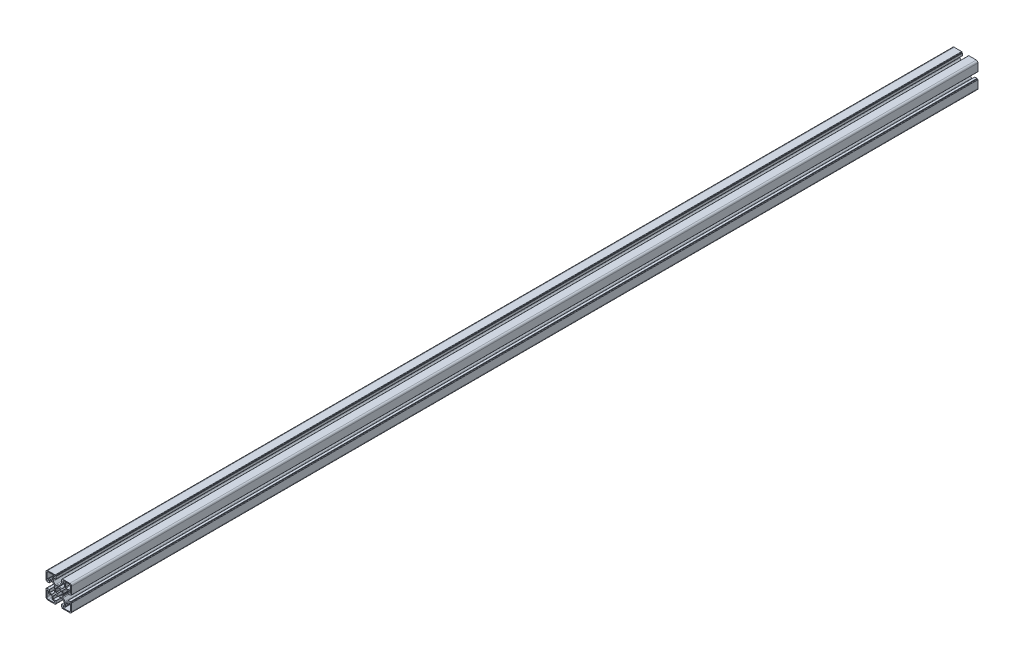
from build123d import *

# Parameters (mm, degrees)
BASE_EXTRUDE_DEPTH  = 1600
M12_HOLE_LEFT_D     = 10.8
M12_HOLE_LEFT_DEPTH = 55
M12_HOLE_LEFT_TIP   = 3.244647343


with BuildPart() as part:
    # Sketch1 → Base-Extrude (new body)
    with BuildSketch(Plane.XY):
        with BuildLine():
            Line((7.973976585, 0.792591518), (7.540060475, 0.046829556))
            ThreePointArc((7.540060475, 0.046829556), (7.534295984, 0.023675638), (7.531329941, 0))
            ThreePointArc((7.531329941, 0), (7.534295984, -0.023675638), (7.540060475, -0.046829556))
            Line((7.540060475, -0.046829556), (7.973976585, -0.792591518))
            ThreePointArc((7.973976585, -0.792591518), (7.996666421, -0.851255641), (8.000014047, -0.914065683))
            ThreePointArc((8.000014047, -0.914065683), (7.719730741, -2.298395946), (7.20036345, -3.611859543))
            ThreePointArc((7.20036345, -3.611859543), (7.018857217, -4.793954471), (7.563483933, -5.85869607))
            Line((7.563483933, -5.85869607), (11.129779889, -9.424988026))
            ThreePointArc((11.129779889, -9.424988026), (11.760624613, -9.84650461), (12.504756513, -9.99452154))
            Line((12.504756513, -9.99452154), (16.316902451, -9.99452154))
            ThreePointArc((16.316902451, -9.99452154), (16.458324055, -9.935942793), (16.516902802, -9.794521189))
            Line((16.516902802, -9.794521189), (16.516902802, -5.200014226))
            ThreePointArc((16.516902802, -5.200014226), (16.575481548, -5.058592621), (16.716903152, -5.000013875))
            Line((16.716903152, -5.000013875), (20.719599904, -5.000013875))
            ThreePointArc((20.719599904, -5.000013875), (20.931731427, -5.087881629), (21.01959918, -5.300013151))
            Line((21.01959918, -5.300013151), (21.01959918, -5.500004099))
            ThreePointArc((21.01959918, -5.500004099), (21.10746708, -5.712135974), (21.319598956, -5.800003874))
            Line((21.319598956, -5.800003874), (21.999979514, -5.800003874))
            ThreePointArc((21.999979514, -5.800003874), (22.35353264, -5.946450374), (22.49997914, -6.300003501))
            Line((22.49997914, -6.300003501), (22.49997914, -19.500016116))
            ThreePointArc((22.49997914, -19.500016116), (21.62130014, -21.621334875), (19.499981381, -22.500013875))
            Line((19.499981381, -22.500013875), (6.375709012, -22.500013875))
            ThreePointArc((6.375709012, -22.500013875), (6.022155886, -22.353567375), (5.875709386, -22.000014249))
            Line((5.875709386, -22.000014249), (5.875709386, -21.30001315))
            ThreePointArc((5.875709386, -21.30001315), (5.787841632, -21.087881628), (5.57571011, -21.000013874))
            Line((5.57571011, -21.000013874), (5.299998776, -21.000013874))
            ThreePointArc((5.299998776, -21.000013874), (5.087867607, -20.912146267), (5, -20.700015099))
            Line((5, -20.700015099), (5, -16.666812433))
            ThreePointArc((5, -16.666812433), (5.058578893, -16.525390475), (5.200000851, -16.466811582))
            Line((5.200000851, -16.466811582), (9.905385218, -16.466811582))
            ThreePointArc((9.905385218, -16.466811582), (10.046806822, -16.408232835), (10.105385569, -16.266811231))
            Line((10.105385569, -16.266811231), (10.105385569, -12.471582956))
            ThreePointArc((10.105385569, -12.471582956), (9.953144588, -11.706215861), (9.519598955, -11.057368968))
            Line((9.519598955, -11.057368968), (5.944897989, -7.482668002))
            ThreePointArc((5.944897989, -7.482668002), (4.854601835, -6.967833724), (3.666499237, -7.173289937))
            ThreePointArc((3.666499237, -7.173289937), (2.309136684, -7.713848333), (0.876396038, -8.000013875))
            ThreePointArc((0.876396038, -8.000013875), (0.81356491, -7.997088573), (0.754749577, -7.974793627))
            Line((0.754749577, -7.974793627), (0.11262846, -7.606936933))
            ThreePointArc((0.11262846, -7.606936933), (0.062963903, -7.559088739), (0, -7.530953975))
            ThreePointArc((0, -7.530953975), (-0.062963903, -7.559088739), (-0.11262846, -7.606936933))
            Line((-0.11262846, -7.606936933), (-0.754749577, -7.974793627))
            ThreePointArc((-0.754749577, -7.974793627), (-0.81356491, -7.997088573), (-0.876396038, -8.000013875))
            ThreePointArc((-0.876396038, -8.000013875), (-2.309136684, -7.713848333), (-3.666499237, -7.173289937))
            ThreePointArc((-3.666499237, -7.173289937), (-4.854601835, -6.967833724), (-5.944897989, -7.482668002))
            Line((-5.944897989, -7.482668002), (-9.519598955, -11.057368968))
            ThreePointArc((-9.519598955, -11.057368968), (-9.953144588, -11.706215861), (-10.105385569, -12.471582956))
            Line((-10.105385569, -12.471582956), (-10.105385569, -16.266811231))
            ThreePointArc((-10.105385569, -16.266811231), (-10.046806822, -16.408232835), (-9.905385218, -16.466811582))
            Line((-9.905385218, -16.466811582), (-5.200000851, -16.466811582))
            ThreePointArc((-5.200000851, -16.466811582), (-5.058578893, -16.525390475), (-5, -16.666812433))
            Line((-5, -16.666812433), (-5, -20.700015099))
            ThreePointArc((-5, -20.700015099), (-5.087867607, -20.912146267), (-5.299998776, -21.000013874))
            Line((-5.299998776, -21.000013874), (-5.57571011, -21.000013874))
            ThreePointArc((-5.57571011, -21.000013874), (-5.787841632, -21.087881628), (-5.875709386, -21.30001315))
            Line((-5.875709386, -21.30001315), (-5.875709386, -22.000014249))
            ThreePointArc((-5.875709386, -22.000014249), (-6.022155886, -22.353567375), (-6.375709012, -22.500013875))
            Line((-6.375709012, -22.500013875), (-19.499981381, -22.500013875))
            ThreePointArc((-19.499981381, -22.500013875), (-21.62130014, -21.621334875), (-22.49997914, -19.500016116))
            Line((-22.49997914, -19.500016116), (-22.49997914, -6.300003501))
            ThreePointArc((-22.49997914, -6.300003501), (-22.35353264, -5.946450374), (-21.999979514, -5.800003874))
            Line((-21.999979514, -5.800003874), (-21.319598956, -5.800003874))
            ThreePointArc((-21.319598956, -5.800003874), (-21.10746708, -5.712135974), (-21.01959918, -5.500004099))
            Line((-21.01959918, -5.500004099), (-21.01959918, -5.300013151))
            ThreePointArc((-21.01959918, -5.300013151), (-20.931731427, -5.087881629), (-20.719599904, -5.000013875))
            Line((-20.719599904, -5.000013875), (-16.716903152, -5.000013875))
            ThreePointArc((-16.716903152, -5.000013875), (-16.575481548, -5.058592621), (-16.516902802, -5.200014226))
            Line((-16.516902802, -5.200014226), (-16.516902802, -9.794521189))
            ThreePointArc((-16.516902802, -9.794521189), (-16.458324055, -9.935942793), (-16.316902451, -9.99452154))
            Line((-16.316902451, -9.99452154), (-12.504756513, -9.99452154))
            ThreePointArc((-12.504756513, -9.99452154), (-11.760624613, -9.84650461), (-11.129779889, -9.424988026))
            Line((-11.129779889, -9.424988026), (-7.563483933, -5.85869607))
            ThreePointArc((-7.563483933, -5.85869607), (-7.018857217, -4.793954471), (-7.20036345, -3.611859543))
            ThreePointArc((-7.20036345, -3.611859543), (-7.719730741, -2.298395946), (-8.000014047, -0.914065683))
            ThreePointArc((-8.000014047, -0.914065683), (-7.996666421, -0.851255641), (-7.973976585, -0.792591518))
            Line((-7.973976585, -0.792591518), (-7.540060475, -0.046829556))
            ThreePointArc((-7.540060475, -0.046829556), (-7.534295984, -0.023675638), (-7.531329941, 0))
            ThreePointArc((-7.531329941, 0), (-7.534295984, 0.023675638), (-7.540060475, 0.046829556))
            Line((-7.540060475, 0.046829556), (-7.973976585, 0.792591518))
            ThreePointArc((-7.973976585, 0.792591518), (-7.996666421, 0.851255641), (-8.000014047, 0.914065683))
            ThreePointArc((-8.000014047, 0.914065683), (-7.719730741, 2.298395946), (-7.20036345, 3.611859543))
            ThreePointArc((-7.20036345, 3.611859543), (-7.018857217, 4.793954471), (-7.563483933, 5.85869607))
            Line((-7.563483933, 5.85869607), (-11.129779889, 9.424988026))
            ThreePointArc((-11.129779889, 9.424988026), (-11.760624613, 9.84650461), (-12.504756513, 9.99452154))
            Line((-12.504756513, 9.99452154), (-16.316902451, 9.99452154))
            ThreePointArc((-16.316902451, 9.99452154), (-16.458324055, 9.935942793), (-16.516902802, 9.794521189))
            Line((-16.516902802, 9.794521189), (-16.516902802, 5.200014226))
            ThreePointArc((-16.516902802, 5.200014226), (-16.575481548, 5.058592621), (-16.716903152, 5.000013875))
            Line((-16.716903152, 5.000013875), (-20.719599904, 5.000013875))
            ThreePointArc((-20.719599904, 5.000013875), (-20.931731427, 5.087881629), (-21.01959918, 5.300013151))
            Line((-21.01959918, 5.300013151), (-21.01959918, 5.500004099))
            ThreePointArc((-21.01959918, 5.500004099), (-21.10746708, 5.712135974), (-21.319598956, 5.800003874))
            Line((-21.319598956, 5.800003874), (-21.999979514, 5.800003874))
            ThreePointArc((-21.999979514, 5.800003874), (-22.35353264, 5.946450374), (-22.49997914, 6.300003501))
            Line((-22.49997914, 6.300003501), (-22.49997914, 19.500016116))
            ThreePointArc((-22.49997914, 19.500016116), (-21.62130014, 21.621334875), (-19.499981381, 22.500013875))
            Line((-19.499981381, 22.500013875), (-6.375709012, 22.500013875))
            ThreePointArc((-6.375709012, 22.500013875), (-6.022155886, 22.353567375), (-5.875709386, 22.000014249))
            Line((-5.875709386, 22.000014249), (-5.875709386, 21.30001315))
            ThreePointArc((-5.875709386, 21.30001315), (-5.787841632, 21.087881628), (-5.57571011, 21.000013874))
            Line((-5.57571011, 21.000013874), (-5.299998776, 21.000013874))
            ThreePointArc((-5.299998776, 21.000013874), (-5.087867607, 20.912146267), (-5, 20.700015099))
            Line((-5, 20.700015099), (-5, 16.666812433))
            ThreePointArc((-5, 16.666812433), (-5.058578893, 16.525390475), (-5.200000851, 16.466811582))
            Line((-5.200000851, 16.466811582), (-9.905385218, 16.466811582))
            ThreePointArc((-9.905385218, 16.466811582), (-10.046806822, 16.408232835), (-10.105385569, 16.266811231))
            Line((-10.105385569, 16.266811231), (-10.105385569, 12.471582956))
            ThreePointArc((-10.105385569, 12.471582956), (-9.953144588, 11.706215861), (-9.519598955, 11.057368968))
            Line((-9.519598955, 11.057368968), (-5.944897989, 7.482668002))
            ThreePointArc((-5.944897989, 7.482668002), (-4.854601835, 6.967833724), (-3.666499237, 7.173289937))
            ThreePointArc((-3.666499237, 7.173289937), (-2.309136684, 7.713848333), (-0.876396038, 8.000013875))
            ThreePointArc((-0.876396038, 8.000013875), (-0.81356491, 7.997088573), (-0.754749577, 7.974793627))
            Line((-0.754749577, 7.974793627), (-0.11262846, 7.606936933))
            ThreePointArc((-0.11262846, 7.606936933), (-0.062963903, 7.559088739), (0, 7.530953975))
            ThreePointArc((0, 7.530953975), (0.062963903, 7.559088739), (0.11262846, 7.606936933))
            Line((0.11262846, 7.606936933), (0.754749577, 7.974793627))
            ThreePointArc((0.754749577, 7.974793627), (0.81356491, 7.997088573), (0.876396038, 8.000013875))
            ThreePointArc((0.876396038, 8.000013875), (2.309136684, 7.713848333), (3.666499237, 7.173289937))
            ThreePointArc((3.666499237, 7.173289937), (4.854601835, 6.967833724), (5.944897989, 7.482668002))
            Line((5.944897989, 7.482668002), (9.519598955, 11.057368968))
            ThreePointArc((9.519598955, 11.057368968), (9.953144588, 11.706215861), (10.105385569, 12.471582956))
            Line((10.105385569, 12.471582956), (10.105385569, 16.266811231))
            ThreePointArc((10.105385569, 16.266811231), (10.046806822, 16.408232835), (9.905385218, 16.466811582))
            Line((9.905385218, 16.466811582), (5.200000851, 16.466811582))
            ThreePointArc((5.200000851, 16.466811582), (5.058578893, 16.525390475), (5, 16.666812433))
            Line((5, 16.666812433), (5, 20.700015099))
            ThreePointArc((5, 20.700015099), (5.087867607, 20.912146267), (5.299998776, 21.000013874))
            Line((5.299998776, 21.000013874), (5.57571011, 21.000013874))
            ThreePointArc((5.57571011, 21.000013874), (5.787841632, 21.087881628), (5.875709386, 21.30001315))
            Line((5.875709386, 21.30001315), (5.875709386, 22.000014249))
            ThreePointArc((5.875709386, 22.000014249), (6.022155886, 22.353567375), (6.375709012, 22.500013875))
            Line((6.375709012, 22.500013875), (19.499981381, 22.500013875))
            ThreePointArc((19.499981381, 22.500013875), (21.62130014, 21.621334875), (22.49997914, 19.500016116))
            Line((22.49997914, 19.500016116), (22.49997914, 6.300003501))
            ThreePointArc((22.49997914, 6.300003501), (22.35353264, 5.946450374), (21.999979514, 5.800003874))
            Line((21.999979514, 5.800003874), (21.319598956, 5.800003874))
            ThreePointArc((21.319598956, 5.800003874), (21.10746708, 5.712135974), (21.01959918, 5.500004099))
            Line((21.01959918, 5.500004099), (21.01959918, 5.300013151))
            ThreePointArc((21.01959918, 5.300013151), (20.931731427, 5.087881629), (20.719599904, 5.000013875))
            Line((20.719599904, 5.000013875), (16.716903152, 5.000013875))
            ThreePointArc((16.716903152, 5.000013875), (16.575481548, 5.058592621), (16.516902802, 5.200014226))
            Line((16.516902802, 5.200014226), (16.516902802, 9.794521189))
            ThreePointArc((16.516902802, 9.794521189), (16.458324055, 9.935942793), (16.316902451, 9.99452154))
            Line((16.316902451, 9.99452154), (12.504756513, 9.99452154))
            ThreePointArc((12.504756513, 9.99452154), (11.760624613, 9.84650461), (11.129779889, 9.424988026))
            Line((11.129779889, 9.424988026), (7.563483933, 5.85869607))
            ThreePointArc((7.563483933, 5.85869607), (7.018857217, 4.793954471), (7.20036345, 3.611859543))
            ThreePointArc((7.20036345, 3.611859543), (7.719730741, 2.298395946), (8.000014047, 0.914065683))
            ThreePointArc((8.000014047, 0.914065683), (7.996666421, 0.851255641), (7.973976585, 0.792591518))
        make_face()
        with BuildLine():
            Line((10.549978885, 18.000013874), (8.999979138, 18.000013874))
            ThreePointArc((8.999979138, 18.000013874), (7.499979138, 19.500013874), (8.999979138, 21.000013874))
            Line((8.999979138, 21.000013874), (18.499981006, 21.000013874))
            ThreePointArc((18.499981006, 21.000013874), (20.267746638, 20.267781374), (20.999979138, 18.500015742))
            Line((20.999979138, 18.500015742), (20.999979138, 9.000204874))
            ThreePointArc((20.999979138, 9.000204874), (19.499979138, 7.500204874), (17.999979138, 9.000204874))
            Line((17.999979138, 9.000204874), (17.999979138, 10.550013621))
            ThreePointArc((17.999979138, 10.550013621), (17.707086138, 11.257119874), (16.999979885, 11.550012874))
            Line((16.999979885, 11.550012874), (12.549977391, 11.550012874))
            ThreePointArc((12.549977391, 11.550012874), (11.842871138, 11.842905874), (11.549978138, 12.550012127))
            Line((11.549978138, 12.550012127), (11.549978138, 17.000014621))
            ThreePointArc((11.549978138, 17.000014621), (11.257085138, 17.707120874), (10.549978885, 18.000013874))
        make_face(mode=Mode.SUBTRACT)
        with BuildLine():
            Line((-0.867388737, 4.924188946), (-0.96752168, 5.481112935))
            ThreePointArc((-0.96752168, 5.481112935), (-1.187855719, 5.829589164), (-1.595071417, 5.894072848))
            ThreePointArc((-1.595071417, 5.894072848), (-2.338895973, 5.643477696), (-3.04438497, 5.299445466))
            ThreePointArc((-3.04438497, 5.299445466), (-3.284615367, 4.964275075), (-3.191311906, 4.562598216))
            Line((-3.191311906, 4.562598216), (-2.864000421, 4.09847552))
            ThreePointArc((-2.864000421, 4.09847552), (-3.53013295, 3.540926624), (-4.08971289, 2.876499344))
            Line((-4.08971289, 2.876499344), (-4.566777651, 3.208162503))
            ThreePointArc((-4.566777651, 3.208162503), (-4.968960845, 3.298770682), (-5.302497889, 3.056460542))
            ThreePointArc((-5.302497889, 3.056460542), (-5.651259984, 2.353310881), (-5.906847665, 1.611199444))
            ThreePointArc((-5.906847665, 1.611199444), (-5.839752063, 1.204293023), (-5.489730697, 0.98621116))
            Line((-5.489730697, 0.98621116), (-4.920545766, 0.887822825))
            ThreePointArc((-4.920545766, 0.887822825), (-4.980096828, 0.445685524), (-5, 0))
            ThreePointArc((-5, 0), (-4.980096828, -0.445685524), (-4.920545766, -0.887822825))
            Line((-4.920545766, -0.887822825), (-5.489730697, -0.98621116))
            ThreePointArc((-5.489730697, -0.98621116), (-5.839752063, -1.204293023), (-5.906847665, -1.611199444))
            ThreePointArc((-5.906847665, -1.611199444), (-5.651259984, -2.353310881), (-5.302497889, -3.056460542))
            ThreePointArc((-5.302497889, -3.056460542), (-4.968960845, -3.298770682), (-4.566777651, -3.208162503))
            Line((-4.566777651, -3.208162503), (-4.08971289, -2.876499344))
            ThreePointArc((-4.08971289, -2.876499344), (-3.53013295, -3.540926624), (-2.864000421, -4.09847552))
            Line((-2.864000421, -4.09847552), (-3.191311906, -4.562598216))
            ThreePointArc((-3.191311906, -4.562598216), (-3.284615367, -4.964275075), (-3.04438497, -5.299445466))
            ThreePointArc((-3.04438497, -5.299445466), (-2.338895973, -5.643477696), (-1.595071417, -5.894072848))
            ThreePointArc((-1.595071417, -5.894072848), (-1.187855719, -5.829589164), (-0.96752168, -5.481112935))
            Line((-0.96752168, -5.481112935), (-0.867388737, -4.924188946))
            ThreePointArc((-0.867388737, -4.924188946), (0, -5), (0.867388737, -4.924188946))
            Line((0.867388737, -4.924188946), (0.96752168, -5.481112935))
            ThreePointArc((0.96752168, -5.481112935), (1.187855719, -5.829589164), (1.595071417, -5.894072848))
            ThreePointArc((1.595071417, -5.894072848), (2.338895973, -5.643477696), (3.04438497, -5.299445466))
            ThreePointArc((3.04438497, -5.299445466), (3.284615367, -4.964275075), (3.191311906, -4.562598216))
            Line((3.191311906, -4.562598216), (2.864000421, -4.09847552))
            ThreePointArc((2.864000421, -4.09847552), (3.53013295, -3.540926624), (4.08971289, -2.876499344))
            Line((4.08971289, -2.876499344), (4.566777651, -3.208162503))
            ThreePointArc((4.566777651, -3.208162503), (4.968960845, -3.298770682), (5.302497889, -3.056460542))
            ThreePointArc((5.302497889, -3.056460542), (5.651259984, -2.353310881), (5.906847665, -1.611199444))
            ThreePointArc((5.906847665, -1.611199444), (5.839752063, -1.204293023), (5.489730697, -0.98621116))
            Line((5.489730697, -0.98621116), (4.920545766, -0.887822825))
            ThreePointArc((4.920545766, -0.887822825), (4.980096828, -0.445685524), (5, 0))
            ThreePointArc((5, 0), (4.980096828, 0.445685524), (4.920545766, 0.887822825))
            Line((4.920545766, 0.887822825), (5.489730697, 0.98621116))
            ThreePointArc((5.489730697, 0.98621116), (5.839752063, 1.204293023), (5.906847665, 1.611199444))
            ThreePointArc((5.906847665, 1.611199444), (5.651259984, 2.353310881), (5.302497889, 3.056460542))
            ThreePointArc((5.302497889, 3.056460542), (4.968960845, 3.298770682), (4.566777651, 3.208162503))
            Line((4.566777651, 3.208162503), (4.08971289, 2.876499344))
            ThreePointArc((4.08971289, 2.876499344), (3.53013295, 3.540926624), (2.864000421, 4.09847552))
            Line((2.864000421, 4.09847552), (3.191311906, 4.562598216))
            ThreePointArc((3.191311906, 4.562598216), (3.284615367, 4.964275075), (3.04438497, 5.299445466))
            ThreePointArc((3.04438497, 5.299445466), (2.338895973, 5.643477696), (1.595071417, 5.894072848))
            ThreePointArc((1.595071417, 5.894072848), (1.187855719, 5.829589164), (0.96752168, 5.481112935))
            Line((0.96752168, 5.481112935), (0.867388737, 4.924188946))
            ThreePointArc((0.867388737, 4.924188946), (0, 5), (-0.867388737, 4.924188946))
        make_face(mode=Mode.SUBTRACT)
        with BuildLine():
            Line((-10.549978885, -18.000013874), (-8.999979138, -18.000013874))
            ThreePointArc((-8.999979138, -18.000013874), (-7.499979138, -19.500013874), (-8.999979138, -21.000013874))
            Line((-8.999979138, -21.000013874), (-18.499981006, -21.000013874))
            ThreePointArc((-18.499981006, -21.000013874), (-20.267746638, -20.267781374), (-20.999979138, -18.500015742))
            Line((-20.999979138, -18.500015742), (-20.999979138, -9.000204874))
            ThreePointArc((-20.999979138, -9.000204874), (-19.499979138, -7.500204874), (-17.999979138, -9.000204874))
            Line((-17.999979138, -9.000204874), (-17.999979138, -10.550013621))
            ThreePointArc((-17.999979138, -10.550013621), (-17.707086138, -11.257119874), (-16.999979885, -11.550012874))
            Line((-16.999979885, -11.550012874), (-12.549977391, -11.550012874))
            ThreePointArc((-12.549977391, -11.550012874), (-11.842871138, -11.842905874), (-11.549978138, -12.550012127))
            Line((-11.549978138, -12.550012127), (-11.549978138, -17.000014621))
            ThreePointArc((-11.549978138, -17.000014621), (-11.257085138, -17.707120874), (-10.549978885, -18.000013874))
        make_face(mode=Mode.SUBTRACT)
        with BuildLine():
            Line((-11.549978138, 12.550012127), (-11.549978138, 17.000014621))
            ThreePointArc((-11.549978138, 17.000014621), (-11.257085138, 17.707120874), (-10.549978885, 18.000013874))
            Line((-10.549978885, 18.000013874), (-8.999979138, 18.000013874))
            ThreePointArc((-8.999979138, 18.000013874), (-7.499979138, 19.500013874), (-8.999979138, 21.000013874))
            Line((-8.999979138, 21.000013874), (-18.499981006, 21.000013874))
            ThreePointArc((-18.499981006, 21.000013874), (-20.267746638, 20.267781374), (-20.999979138, 18.500015742))
            Line((-20.999979138, 18.500015742), (-20.999979138, 9.000204874))
            ThreePointArc((-20.999979138, 9.000204874), (-19.499979138, 7.500204874), (-17.999979138, 9.000204874))
            Line((-17.999979138, 9.000204874), (-17.999979138, 10.550013621))
            ThreePointArc((-17.999979138, 10.550013621), (-17.707086138, 11.257119874), (-16.999979885, 11.550012874))
            Line((-16.999979885, 11.550012874), (-12.549977391, 11.550012874))
            ThreePointArc((-12.549977391, 11.550012874), (-11.842871138, 11.842905874), (-11.549978138, 12.550012127))
        make_face(mode=Mode.SUBTRACT)
        with BuildLine():
            Line((11.549978138, -12.550012127), (11.549978138, -17.000014621))
            ThreePointArc((11.549978138, -17.000014621), (11.257085138, -17.707120874), (10.549978885, -18.000013874))
            Line((10.549978885, -18.000013874), (8.999979138, -18.000013874))
            ThreePointArc((8.999979138, -18.000013874), (7.499979138, -19.500013874), (8.999979138, -21.000013874))
            Line((8.999979138, -21.000013874), (18.499981006, -21.000013874))
            ThreePointArc((18.499981006, -21.000013874), (20.267746638, -20.267781374), (20.999979138, -18.500015742))
            Line((20.999979138, -18.500015742), (20.999979138, -9.000204874))
            ThreePointArc((20.999979138, -9.000204874), (19.499979138, -7.500204874), (17.999979138, -9.000204874))
            Line((17.999979138, -9.000204874), (17.999979138, -10.550013621))
            ThreePointArc((17.999979138, -10.550013621), (17.707086138, -11.257119874), (16.999979885, -11.550012874))
            Line((16.999979885, -11.550012874), (12.549977391, -11.550012874))
            ThreePointArc((12.549977391, -11.550012874), (11.842871138, -11.842905874), (11.549978138, -12.550012127))
        make_face(mode=Mode.SUBTRACT)
    extrude(amount=-BASE_EXTRUDE_DEPTH)

    # M12 Hole Left
    with Locations(Plane.XY):
        with Locations((0, 0)):
            Hole(M12_HOLE_LEFT_D / 2, depth=M12_HOLE_LEFT_DEPTH)
            with Locations((0, 0, -(M12_HOLE_LEFT_DEPTH + M12_HOLE_LEFT_TIP / 2))):  # 118° drill point
                Cone(0, M12_HOLE_LEFT_D / 2, M12_HOLE_LEFT_TIP, mode=Mode.SUBTRACT)


solid = part.part
